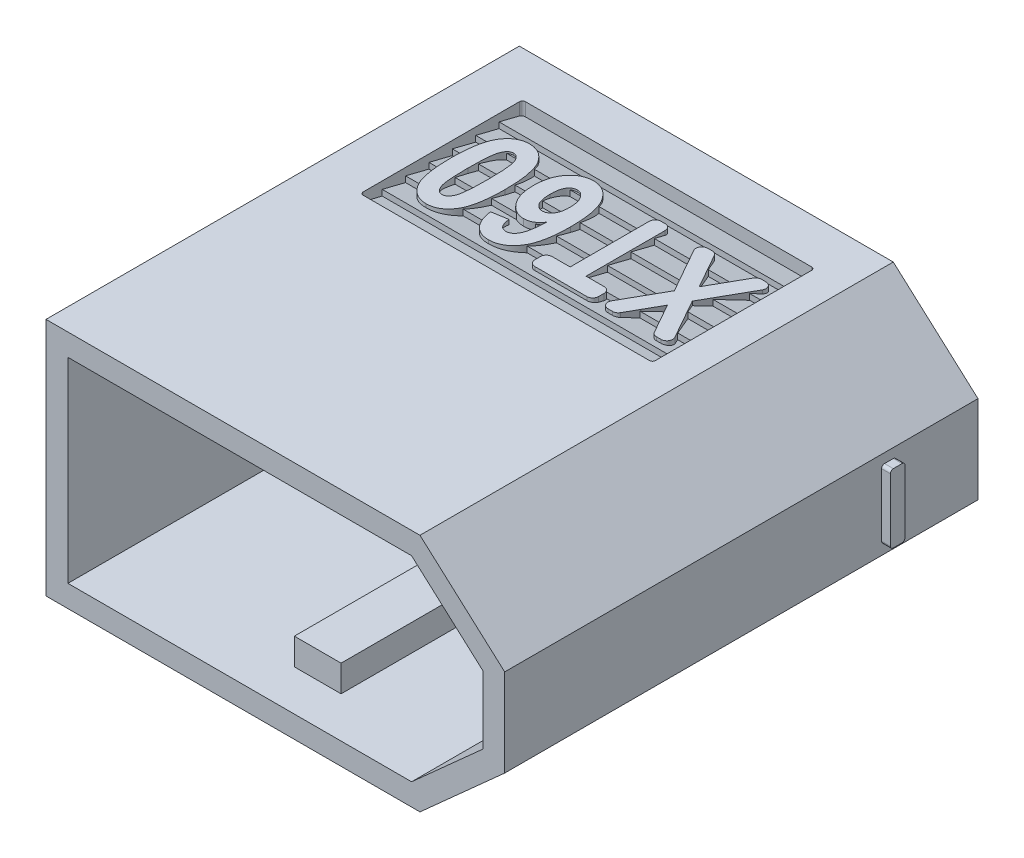
from build123d import *

# Parameters (mm, degrees)
RESSALTO_EXTRUS_O1_DEPTH = 16.2
CORTE_EXTRUS_O1_DEPTH    = 9.4
ESBO_O3_W                = 1.6
ESBO_O3_H                = 0.91
RESSALTO_EXTRUS_O2_DEPTH = 8
ESBO_O4_W                = 1.6
ESBO_O4_H                = 4.7
CORTE_EXTRUS_O2_DEPTH    = 1.5
ESBO_O5_R                = 3
CORTE_EXTRUS_O3_DEPTH    = 2
ESBO_O6_R                = 2.15
CORTE_EXTRUS_O4_DEPTH    = 15.2
RESSALTO_EXTRUS_O3_DEPTH = 0.3
RESSALTO_EXTRUS_O4_DEPTH = 0.3
CORTE_EXTRUS_O5_DEPTH    = 0.75
RESSALTO_EXTRUS_O7_DEPTH = 10
RESSALTO_EXTRUS_O8_DEPTH = 0.3
RESSALTO_EXTRUS_O9_DEPTH = 0.3


with BuildPart() as part:
    # Esboço1 → Ressalto-extrusão1 (new body)
    with BuildSketch(Plane.XY):
        Polygon((0, 0), (12.8, 0), (15.7, 2.6), (15.7, 5.6), (12.8, 8.2), (0, 8.2), align=None)
    extrude(amount=RESSALTO_EXTRUS_O1_DEPTH)

    # Esboço2 → Corte-extrusão1 (cut)
    with BuildSketch(Plane.XY.offset(16.2)):
        Polygon((0.75, 7.45), (0.75, 0.75), (12.513018725, 0.75), (14.95, 2.934879763), (14.95, 5.265120237), (12.513018725, 7.45), align=None)
    extrude(amount=-CORTE_EXTRUS_O1_DEPTH, mode=Mode.SUBTRACT)

    # Esboço3 → Ressalto-extrusão2 (add)
    with BuildSketch(Plane.XY.offset(6.8)):
        with Locations((7.9, 1.205)):
            Rectangle(ESBO_O3_W, ESBO_O3_H)
    extrude(amount=RESSALTO_EXTRUS_O2_DEPTH)

    # Esboço4 → Corte-extrusão2 (cut)
    with BuildSketch(Plane.XY.offset(6.8)):
        with Locations((7.9, 4.1)):
            Rectangle(ESBO_O4_W, ESBO_O4_H)
    extrude(amount=-CORTE_EXTRUS_O2_DEPTH, mode=Mode.SUBTRACT)

    # Esboço5 → Corte-extrusão3 (cut)
    with BuildSketch(Plane(origin=(0, 0, 0), x_dir=(-1, 0, 0), z_dir=(0, 0, -1))):
        with Locations((-11.35, 4.1)):
            Circle(ESBO_O5_R)
        with Locations((-4.25, 4.1)):
            Circle(ESBO_O5_R)
    extrude(amount=-CORTE_EXTRUS_O3_DEPTH, mode=Mode.SUBTRACT)

    # Esboço6 → Corte-extrusão4 (cut, through all)
    with BuildSketch(Plane(origin=(0, 0, 2), x_dir=(-1, 0, 0), z_dir=(0, 0, -1))):
        with Locations((-11.35, 4.1)):
            Circle(ESBO_O6_R)
        with Locations((-4.25, 4.1)):
            Circle(ESBO_O6_R)
    extrude(amount=-CORTE_EXTRUS_O4_DEPTH, mode=Mode.SUBTRACT)

    # Esboço7 → Ressalto-extrusão3 (add)
    with BuildSketch(Plane.ZY):
        with BuildLine():
            Line((2.8, 4.35), (2.05, 4.35))
            ThreePointArc((2.05, 4.35), (1.979289322, 4.320710678), (1.95, 4.25))
            Line((1.95, 4.25), (1.95, 3.95))
            ThreePointArc((1.95, 3.95), (1.979289322, 3.879289322), (2.05, 3.85))
            Line((2.05, 3.85), (2.8, 3.85))
            ThreePointArc((2.8, 3.85), (2.870710678, 3.820710678), (2.9, 3.75))
            Line((2.9, 3.75), (2.9, 3))
            ThreePointArc((2.9, 3), (2.929289322, 2.929289322), (3, 2.9))
            Line((3, 2.9), (3.3, 2.9))
            ThreePointArc((3.3, 2.9), (3.370710678, 2.929289322), (3.4, 3))
            Line((3.4, 3), (3.4, 3.75))
            ThreePointArc((3.4, 3.75), (3.429289322, 3.820710678), (3.5, 3.85))
            Line((3.5, 3.85), (4.25, 3.85))
            ThreePointArc((4.25, 3.85), (4.320710678, 3.879289322), (4.35, 3.95))
            Line((4.35, 3.95), (4.35, 4.25))
            ThreePointArc((4.35, 4.25), (4.320710678, 4.320710678), (4.25, 4.35))
            Line((4.25, 4.35), (3.5, 4.35))
            ThreePointArc((3.5, 4.35), (3.429289322, 4.379289322), (3.4, 4.45))
            Line((3.4, 4.45), (3.4, 5.2))
            ThreePointArc((3.4, 5.2), (3.370710678, 5.270710678), (3.3, 5.3))
            Line((3.3, 5.3), (3, 5.3))
            ThreePointArc((3, 5.3), (2.929289322, 5.270710678), (2.9, 5.2))
            Line((2.9, 5.2), (2.9, 4.45))
            ThreePointArc((2.9, 4.45), (2.870710678, 4.379289322), (2.8, 4.35))
        make_face()
    extrude(amount=RESSALTO_EXTRUS_O3_DEPTH)

    # Esboço8 → Ressalto-extrusão4 (add)
    with BuildSketch(Plane(origin=(15.7, 0, 0), x_dir=(0, 0, -1), z_dir=(1, 0, 0))):
        with BuildLine():
            Line((-3.2, 2.925), (-2.9, 2.925))
            ThreePointArc((-2.9, 2.925), (-2.829289322, 2.954289322), (-2.8, 3.025))
            Line((-2.8, 3.025), (-2.8, 5.175))
            ThreePointArc((-2.8, 5.175), (-2.829289322, 5.245710678), (-2.9, 5.275))
            Line((-2.9, 5.275), (-3.2, 5.275))
            ThreePointArc((-3.2, 5.275), (-3.270710678, 5.245710678), (-3.3, 5.175))
            Line((-3.3, 5.175), (-3.3, 3.025))
            ThreePointArc((-3.3, 3.025), (-3.270710678, 2.954289322), (-3.2, 2.925))
        make_face()
    extrude(amount=RESSALTO_EXTRUS_O4_DEPTH)

    # Esboço9 → Corte-extrusão5 (cut)
    with BuildSketch(Plane.XZ):
        with BuildLine():
            Line((1.75, 7.093123445), (11.55, 7.093123445))
            ThreePointArc((11.55, 7.093123445), (11.620710678, 7.063834123), (11.65, 6.993123445))
            Line((11.65, 6.993123445), (11.65, 1.643123445))
            ThreePointArc((11.65, 1.643123445), (11.620710678, 1.572412766), (11.55, 1.543123445))
            Line((11.55, 1.543123445), (1.75, 1.543123445))
            ThreePointArc((1.75, 1.543123445), (1.679289322, 1.572412766), (1.65, 1.643123445))
            Line((1.65, 1.643123445), (1.65, 6.993123445))
            ThreePointArc((1.65, 6.993123445), (1.679289322, 7.063834123), (1.75, 7.093123445))
        make_face()
    corte_extrus_o5 = extrude(amount=-CORTE_EXTRUS_O5_DEPTH, mode=Mode.SUBTRACT)

    # Esboço10 → Ressalto-extrusão7 (add)
    with BuildSketch(Plane(origin=(1.65, 0, 0), x_dir=(0, 0, -1), z_dir=(1, 0, 0))):
        Polygon((-3.143123445, 0.45), (-3.143123445, 0.25), (-2.343123445, 0.45), (-2.343123445, 0.25), (-1.543123445, 0.45), (-1.543123445, 0.75), (-7.143123445, 0.75), (-7.143123445, 0.45), (-7.143123445, 0.25), (-6.343123445, 0.45), (-6.343123445, 0.25), (-5.543123445, 0.45), (-5.543123445, 0.25), (-4.743123445, 0.45), (-4.743123445, 0.25), (-3.943123445, 0.45), (-3.943123445, 0.25), align=None)
    ressalto_extrus_o7 = extrude(amount=RESSALTO_EXTRUS_O7_DEPTH)

    # Espelhar1: Corte-extrusão5, Ressalto-extrusão7 across plane
    add(corte_extrus_o5.mirror(Plane.ZX.offset(4.1)), mode=Mode.SUBTRACT)
    add(ressalto_extrus_o7.mirror(Plane.ZX.offset(4.1)))

    # Esboço11 → Ressalto-extrusão8 (add)
    with BuildSketch(Plane(origin=(0, 0.5, 0), x_dir=(-1, 0, 0), z_dir=(0, -1, 0))):
        with BuildLine():
            add(Edge.make_bspline(
                [(-5.023961169, -6.00435038), (-5.023731287, -5.995665006), (-5.023167139, -5.974350412), (-5.020606597, -5.937326865), (-5.015634685, -5.891913541), (-5.008374694, -5.840781928), (-4.996852924, -5.786628833), (-4.98507998, -5.730621834), (-4.970342979, -5.676032154), (-4.952923205, -5.625615372), (-4.932961076, -5.58080345), (-4.908069139, -5.546064886), (-4.881021, -5.518802059), (-4.858555504, -5.515226002), (-4.848332577, -5.513598717)],
                knots=[0, 0, 0, 0, 2.6064e-05, 6.3962e-05, 0.00011129, 0.000163105, 0.000218808, 0.000277324, 0.000334811, 0.00038823, 0.000437474, 0.000480846, 0.000517214, 0.000547583, 0.000547583, 0.000547583, 0.000547583], degree=3))
            Line((-4.848332577, -5.513598717), (-4.020609309, -5.513598717))
            Line((-4.020609309, -5.513598717), (-3.49036222, -2.555643484))
            add(Edge.make_bspline(
                [(-3.49036222, -2.555643484), (-3.487094486, -2.546511208), (-3.480493928, -2.528064751), (-3.462940698, -2.502333792), (-3.435671591, -2.480838398), (-3.397551986, -2.465314687), (-3.349369795, -2.453459182), (-3.289027368, -2.44320829), (-3.214317598, -2.436547775), (-3.159289179, -2.436398815), (-3.129021098, -2.436316881)],
                knots=[0, 0, 0, 0, 2.9025e-05, 5.8628e-05, 9.2093e-05, 0.000131598, 0.000181127, 0.000240808, 0.000315062, 0.000405833, 0.000405833, 0.000405833, 0.000405833], degree=3))
            add(Edge.make_bspline(
                [(-3.129021098, -2.436316881), (-3.099590319, -2.436400624), (-3.045954651, -2.43655324), (-2.973504555, -2.44319605), (-2.916339343, -2.453001646), (-2.873392308, -2.464895138), (-2.841745516, -2.480373872), (-2.823600732, -2.503205048), (-2.815413627, -2.529106558), (-2.817188659, -2.546643114), (-2.818099667, -2.555643484)],
                knots=[0, 0, 0, 0, 8.825e-05, 0.000160831, 0.000218029, 0.000261895, 0.000294625, 0.000321528, 0.000347044, 0.000373948, 0.000373948, 0.000373948, 0.000373948], degree=3))
            Line((-2.818099667, -2.555643484), (-3.348346756, -5.513598717))
            Line((-3.348346756, -5.513598717), (-2.527346113, -5.513598717))
            add(Edge.make_bspline(
                [(-2.527346113, -5.513598717), (-2.5158995, -5.51461475), (-2.493831667, -5.516573553), (-2.472715893, -5.546733002), (-2.463160736, -5.584517711), (-2.462285798, -5.613492933), (-2.461800514, -5.629564007)],
                knots=[0, 0, 0, 0, 3.2816e-05, 6.3265e-05, 0.00010182, 0.000149836, 0.000149836, 0.000149836, 0.000149836], degree=3))
            add(Edge.make_bspline(
                [(-2.461800514, -5.629564007), (-2.461977539, -5.638813278), (-2.462407487, -5.661277307), (-2.466216965, -5.699071845), (-2.470998184, -5.745356077), (-2.478414587, -5.796958197), (-2.488582941, -5.852446205), (-2.500798033, -5.908853075), (-2.514928426, -5.964134452), (-2.534662336, -6.013696946), (-2.55458049, -6.057861337), (-2.578178377, -6.092213603), (-2.605428151, -6.117627625), (-2.627240684, -6.121178211), (-2.637429106, -6.122836655)],
                knots=[0, 0, 0, 0, 2.7744e-05, 6.7382e-05, 0.000113874, 0.000167352, 0.000223723, 0.00028306, 0.000340547, 0.000394545, 0.000443029, 0.00048523, 0.000519878, 0.000550246, 0.000550246, 0.000550246, 0.000550246], degree=3))
            Line((-2.637429106, -6.122836655), (-4.960096227, -6.122836655))
            add(Edge.make_bspline(
                [(-4.960096227, -6.122836655), (-4.969934281, -6.121426251), (-4.99037917, -6.118495228), (-5.011571026, -6.089692698), (-5.021864767, -6.050856537), (-5.023211361, -6.020983972), (-5.023961169, -6.00435038)],
                knots=[0, 0, 0, 0, 2.8744e-05, 5.9733e-05, 9.9336e-05, 0.000149093, 0.000149093, 0.000149093, 0.000149093], degree=3))
        make_face()
        with BuildLine():
            add(Edge.make_bspline(
                [(-8.005445591, -5.732084047), (-8.005233805, -5.721157588), (-8.004755518, -5.69648183), (-8.002257862, -5.656087157), (-7.997216524, -5.609824927), (-7.989672588, -5.559640101), (-7.979672262, -5.507819052), (-7.968127736, -5.455855322), (-7.954624636, -5.406442246), (-7.937593996, -5.361995207), (-7.919841845, -5.322908562), (-7.899498565, -5.292757131), (-7.878287508, -5.269109619), (-7.86042282, -5.265583769), (-7.852505861, -5.264021244)],
                knots=[0, 0, 0, 0, 3.2784e-05, 7.4037e-05, 0.000121364, 0.000172348, 0.000226241, 0.000279653, 0.000332057, 0.00037966, 0.000422509, 0.000460033, 0.000489767, 0.000513431, 0.000513431, 0.000513431, 0.000513431], degree=3))
            add(Edge.make_bspline(
                [(-7.852505861, -5.264021244), (-7.845452061, -5.264904506), (-7.829851748, -5.266857944), (-7.804797296, -5.276024895), (-7.776406148, -5.29162043), (-7.730609729, -5.322094595), (-7.661287561, -5.366554766), (-7.562598175, -5.424293206), (-7.440427841, -5.481447336), (-7.322385437, -5.522805842), (-7.215484092, -5.550613186), (-7.125251104, -5.565599411), (-7.027726856, -5.57352652), (-6.960370911, -5.575015091), (-6.925623866, -5.575783003)],
                knots=[0, 0, 0, 0, 2.1275e-05, 4.7053e-05, 7.9381e-05, 0.000118309, 0.00021202, 0.000326465, 0.000461046, 0.000615988, 0.000700978, 0.000792156, 0.000889996, 0.000994251, 0.000994251, 0.000994251, 0.000994251], degree=3))
            add(Edge.make_bspline(
                [(-6.925623866, -5.575783003), (-6.890276179, -5.575112001), (-6.820714939, -5.573791525), (-6.71881609, -5.559310648), (-6.620879787, -5.539244265), (-6.528038512, -5.508289798), (-6.439439434, -5.470183053), (-6.354808917, -5.425881372), (-6.274209796, -5.374938124), (-6.197898312, -5.317782161), (-6.125337935, -5.254656842), (-6.057780279, -5.185519577), (-5.993086757, -5.112490516), (-5.915245473, -5.00655333), (-5.827853488, -4.865004138), (-5.741758712, -4.683337999), (-5.673142777, -4.492613249), (-5.626520902, -4.295160578), (-5.595410147, -4.096109002), (-5.592019032, -3.96274579), (-5.59034237, -3.896807277)],
                knots=[0, 0, 0, 0, 0.000105965, 0.000208529, 0.000308246, 0.000405506, 0.000501502, 0.000597351, 0.000691772, 0.000787233, 0.000883122, 0.000979979, 0.001077054, 0.001175541, 0.001374003, 0.001575094, 0.001777629, 0.001980832, 0.002182981, 0.002380675, 0.002380675, 0.002380675, 0.002380675], degree=3))
            add(Edge.make_bspline(
                [(-5.59034237, -3.896807277), (-5.590871805, -3.861481942), (-5.591899808, -3.792890748), (-5.603110001, -3.693712719), (-5.620667577, -3.601229886), (-5.644851035, -3.51534807), (-5.675878531, -3.435840868), (-5.713888363, -3.363292733), (-5.757702979, -3.297278928), (-5.807513278, -3.237950776), (-5.863357452, -3.185891772), (-5.924157557, -3.139448548), (-5.992135639, -3.102310572), (-6.064487022, -3.070033176), (-6.14190109, -3.044779053), (-6.224178948, -3.027460146), (-6.310743564, -3.016057319), (-6.370129331, -3.015001296), (-6.400418746, -3.014462676)],
                knots=[0, 0, 0, 0, 0.000105935, 0.000205693, 0.000298974, 0.000388084, 0.000472974, 0.000554538, 0.000633314, 0.000710244, 0.000786339, 0.000861968, 0.0009391, 0.001018109, 0.001099426, 0.001182826, 0.001270066, 0.001360884, 0.001360884, 0.001360884, 0.001360884], degree=3))
            add(Edge.make_bspline(
                [(-6.400418746, -3.014462676), (-6.441984642, -3.015611215), (-6.525415258, -3.017916548), (-6.647858981, -3.041043496), (-6.766205581, -3.074435661), (-6.838672757, -3.110262009), (-6.874363846, -3.127906982)],
                knots=[0, 0, 0, 0, 0.00012455, 0.000249996, 0.000372822, 0.000492024, 0.000492024, 0.000492024, 0.000492024], degree=3))
            Line((-6.874363846, -3.127906982), (-7.027303577, -3.975798127))
            Line((-7.027303577, -3.975798127), (-6.405460715, -3.975798127))
            add(Edge.make_bspline(
                [(-6.405460715, -3.975798127), (-6.396032338, -3.977054064), (-6.376498001, -3.979656199), (-6.354225524, -4.004786531), (-6.340822506, -4.042285405), (-6.340248828, -4.071973018), (-6.339915116, -4.089242433)],
                knots=[0, 0, 0, 0, 2.7718e-05, 5.7428e-05, 9.4412e-05, 0.000145844, 0.000145844, 0.000145844, 0.000145844], degree=3))
            add(Edge.make_bspline(
                [(-6.339915116, -4.089242433), (-6.340007123, -4.100178481), (-6.34021529, -4.124921501), (-6.345257389, -4.164911883), (-6.350408738, -4.210435976), (-6.359386856, -4.258457362), (-6.368207285, -4.308513896), (-6.379561212, -4.358263352), (-6.393351556, -4.406000103), (-6.410607636, -4.448661231), (-6.431034, -4.484869643), (-6.451535593, -4.514643738), (-6.476695242, -4.535852891), (-6.496191515, -4.539001749), (-6.50545977, -4.540498671)],
                knots=[0, 0, 0, 0, 3.2784e-05, 7.4173e-05, 0.000120764, 0.000170222, 0.000220656, 0.000273249, 0.000323233, 0.00036958, 0.000410962, 0.0004476, 0.000478189, 0.000505907, 0.000505907, 0.000505907, 0.000505907], degree=3))
            Line((-6.50545977, -4.540498671), (-7.618054295, -4.540498671))
            add(Edge.make_bspline(
                [(-7.618054295, -4.540498671), (-7.631028748, -4.539695256), (-7.655886414, -4.538155997), (-7.690371762, -4.526433837), (-7.718598065, -4.50614808), (-7.74018276, -4.478209964), (-7.754374786, -4.44306982), (-7.760248857, -4.401532584), (-7.761457637, -4.353981025), (-7.756174688, -4.320568781), (-7.753347134, -4.302685793)],
                knots=[0, 0, 0, 0, 3.8883e-05, 7.4495e-05, 0.000107611, 0.000141735, 0.000179033, 0.000219925, 0.000266991, 0.00032119, 0.00032119, 0.00032119, 0.00032119], degree=3))
            Line((-7.753347134, -4.302685793), (-7.488643754, -2.832951787))
            add(Edge.make_bspline(
                [(-7.488643754, -2.832951787), (-7.484932567, -2.816378345), (-7.478008418, -2.785456437), (-7.46492174, -2.741793185), (-7.446178544, -2.7041663), (-7.430134023, -2.682328748), (-7.422257827, -2.671608774)],
                knots=[0, 0, 0, 0, 5.0956e-05, 9.5071e-05, 0.00013641, 0.00017627, 0.00017627, 0.00017627, 0.00017627], degree=3))
            add(Edge.make_bspline(
                [(-7.422257827, -2.671608774), (-7.416231591, -2.665574456), (-7.402120311, -2.651444251), (-7.37426183, -2.631630505), (-7.336320112, -2.612116828), (-7.271721396, -2.580005779), (-7.173655195, -2.540224112), (-7.038673137, -2.495401693), (-6.884344834, -2.453408859), (-6.714006485, -2.419933315), (-6.533346086, -2.394808927), (-6.409750166, -2.392235662), (-6.34747807, -2.390939158)],
                knots=[0, 0, 0, 0, 2.5558e-05, 5.9847e-05, 0.000101964, 0.000153451, 0.000276268, 0.000418968, 0.000580007, 0.000755685, 0.000939548, 0.001126254, 0.001126254, 0.001126254, 0.001126254], degree=3))
            add(Edge.make_bspline(
                [(-6.34747807, -2.390939158), (-6.290017279, -2.392085578), (-6.17847988, -2.394310898), (-6.016534188, -2.41097196), (-5.865393213, -2.439681829), (-5.724343707, -2.47847325), (-5.594644173, -2.53031849), (-5.474482576, -2.59117225), (-5.366924212, -2.665978248), (-5.269134234, -2.750285511), (-5.183278961, -2.846044213), (-5.107514929, -2.951618377), (-5.045184949, -3.068619941), (-4.991498741, -3.194272892), (-4.950571377, -3.330444745), (-4.92155039, -3.476194463), (-4.903510692, -3.631932588), (-4.901479969, -3.739054811), (-4.900432925, -3.794287238)],
                knots=[0, 0, 0, 0, 0.000172368, 0.000334584, 0.000487692, 0.000633478, 0.000772671, 0.000906096, 0.001036626, 0.00116469, 0.00129261, 0.001421556, 0.001553541, 0.001689482, 0.001830902, 0.001979224, 0.002134848, 0.002300497, 0.002300497, 0.002300497, 0.002300497], degree=3))
            add(Edge.make_bspline(
                [(-4.900432925, -3.794287238), (-4.900905574, -3.845294829), (-4.901844387, -3.946610285), (-4.914742729, -4.097966778), (-4.932583422, -4.247805266), (-4.958701667, -4.395928796), (-4.99253789, -4.541087834), (-5.032356058, -4.683657708), (-5.081529457, -4.821948844), (-5.13678848, -4.956828646), (-5.199584663, -5.086811605), (-5.270198263, -5.211779027), (-5.345934724, -5.33288119), (-5.430056432, -5.447884454), (-5.521068083, -5.55643969), (-5.618182845, -5.658754515), (-5.724187844, -5.75176642), (-5.835355528, -5.838862544), (-5.954599059, -5.916135709), (-6.079758992, -5.985133465), (-6.211692275, -6.045266744), (-6.350247896, -6.095365279), (-6.495259856, -6.136376965), (-6.647191877, -6.164275874), (-6.805564122, -6.182714335), (-6.913525434, -6.184799742), (-6.968480603, -6.18586127)],
                knots=[0, 0, 0, 0, 0.000152977, 0.000303855, 0.000455405, 0.00060558, 0.000754792, 0.000902424, 0.001049395, 0.001194838, 0.001339535, 0.001482126, 0.001625271, 0.001767803, 0.00190918, 0.002050037, 0.002190516, 0.002331876, 0.002473353, 0.002616271, 0.002760301, 0.002907837, 0.003057897, 0.00321183, 0.003370795, 0.003535604, 0.003535604, 0.003535604, 0.003535604], degree=3))
            add(Edge.make_bspline(
                [(-6.968480603, -6.18586127), (-7.0290792, -6.184331494), (-7.147145904, -6.18135097), (-7.317412746, -6.155941012), (-7.473193069, -6.119872726), (-7.612804056, -6.077894875), (-7.732975101, -6.029341039), (-7.819588267, -5.98510127), (-7.876269531, -5.949103523), (-7.909395725, -5.926063462), (-7.935436602, -5.907072311), (-7.960438269, -5.88640523), (-7.981066611, -5.858738461), (-7.997461203, -5.821981054), (-8.004140504, -5.77910018), (-8.004986589, -5.74861974), (-8.005445591, -5.732084047)],
                knots=[0, 0, 0, 0, 0.000181705, 0.000354024, 0.000515266, 0.000661196, 0.000790871, 0.000903628, 0.000952353, 0.000992213, 0.00102465, 0.001049077, 0.001089246, 0.001126874, 0.001168739, 0.001218382, 0.001218382, 0.001218382, 0.001218382], degree=3))
        make_face()
        with BuildLine():
            Line((-9.699547225, -3.845547257), (-9.470137629, -2.552282171))
            add(Edge.make_bspline(
                [(-9.470137629, -2.552282171), (-9.466859766, -2.543161727), (-9.460238748, -2.52473917), (-9.442946515, -2.498964908), (-9.414937846, -2.478219246), (-9.376716334, -2.463027083), (-9.328197381, -2.450399387), (-9.267224842, -2.442997509), (-9.192960802, -2.436667812), (-9.138508583, -2.436440768), (-9.108796506, -2.436316881)],
                knots=[0, 0, 0, 0, 2.9025e-05, 5.8628e-05, 9.1572e-05, 0.000131847, 0.000181376, 0.000241629, 0.000315811, 0.000404902, 0.000404902, 0.000404902, 0.000404902], degree=3))
            add(Edge.make_bspline(
                [(-9.108796506, -2.436316881), (-9.07908089, -2.4364132), (-9.025460301, -2.436587003), (-8.953170251, -2.442958428), (-8.895984093, -2.450121251), (-8.853113738, -2.462392488), (-8.821882373, -2.47787117), (-8.803149573, -2.499931887), (-8.795230917, -2.525777934), (-8.796978272, -2.543292888), (-8.797875076, -2.552282171)],
                knots=[0, 0, 0, 0, 8.9091e-05, 0.00016076, 0.000217686, 0.000261552, 0.000294282, 0.000320535, 0.000346051, 0.000372955, 0.000372955, 0.000372955, 0.000372955], degree=3))
            Line((-8.797875076, -2.552282171), (-9.027284672, -3.845547257))
            Line((-9.027284672, -3.845547257), (-8.486953645, -5.845528352))
            add(Edge.make_bspline(
                [(-8.486953645, -5.845528352), (-8.478833829, -5.87511468), (-8.464477661, -5.927424524), (-8.452459229, -5.997552522), (-8.451114009, -6.053647581), (-8.470343992, -6.090049885), (-8.495365993, -6.108483462), (-8.519933136, -6.118787125), (-8.549846675, -6.127196016), (-8.58564508, -6.132928512), (-8.62837865, -6.135711651), (-8.678523457, -6.13827363), (-8.736802258, -6.139884763), (-8.778266582, -6.140275181), (-8.80039606, -6.140483547)],
                knots=[0, 0, 0, 0, 9.1919e-05, 0.000162517, 0.000213839, 0.000257097, 0.000279282, 0.000305988, 0.000336577, 0.000372357, 0.000414508, 0.000464991, 0.000522998, 0.000589389, 0.000589389, 0.000589389, 0.000589389], degree=3))
            add(Edge.make_bspline(
                [(-8.80039606, -6.140483547), (-8.832318453, -6.140341829), (-8.888907188, -6.140090606), (-8.964273956, -6.138021895), (-9.021780456, -6.129917263), (-9.066180039, -6.120808034), (-9.098903106, -6.102781231), (-9.120223894, -6.076561798), (-9.13175067, -6.04348518), (-9.138106211, -6.019785287), (-9.141569306, -6.006871365)],
                knots=[0, 0, 0, 0, 9.5801e-05, 0.000169826, 0.000225801, 0.000270028, 0.000305051, 0.000335501, 0.000369051, 0.00040922, 0.00040922, 0.00040922, 0.00040922], degree=3))
            Line((-9.141569306, -6.006871365), (-9.363415948, -5.124526764))
            add(Edge.make_bspline(
                [(-9.363415948, -5.124526764), (-9.375252204, -5.073003414), (-9.398319243, -4.972592338), (-9.4313429, -4.82328113), (-9.459458724, -4.674488444), (-9.474906837, -4.574439649), (-9.482742551, -4.523692108)],
                knots=[0, 0, 0, 0, 0.000158597, 0.000309082, 0.000458731, 0.00061277, 0.00061277, 0.00061277, 0.00061277], degree=3))
            Line((-9.482742551, -4.523692108), (-9.487784521, -4.523692108))
            add(Edge.make_bspline(
                [(-9.487784521, -4.523692108), (-9.511639997, -4.574225455), (-9.559347354, -4.675284529), (-9.635013885, -4.824621142), (-9.714451456, -4.972922929), (-9.770445333, -5.070325057), (-9.798705951, -5.119484795)],
                knots=[0, 0, 0, 0, 0.000167637, 0.000335248, 0.000502177, 0.000672281, 0.000672281, 0.000672281, 0.000672281], degree=3))
            Line((-9.798705951, -5.119484795), (-10.326432055, -6.015274647))
            add(Edge.make_bspline(
                [(-10.326432055, -6.015274647), (-10.333247008, -6.02658162), (-10.346131701, -6.047959155), (-10.367813932, -6.077469508), (-10.397293269, -6.100071343), (-10.435252647, -6.11659373), (-10.484479232, -6.127846444), (-10.547170712, -6.136190535), (-10.628360793, -6.139453445), (-10.688895234, -6.140111868), (-10.723066962, -6.140483547)],
                knots=[0, 0, 0, 0, 3.9638e-05, 7.4942e-05, 0.000109066, 0.000149681, 0.000198187, 0.000260104, 0.000339207, 0.000441741, 0.000441741, 0.000441741, 0.000441741], degree=3))
            add(Edge.make_bspline(
                [(-10.723066962, -6.140483547), (-10.746315279, -6.140244969), (-10.789737126, -6.139799365), (-10.850571208, -6.138566379), (-10.902659649, -6.134868561), (-10.946544735, -6.131420338), (-10.982700322, -6.124853597), (-11.011731032, -6.115530144), (-11.035346625, -6.104645101), (-11.05126765, -6.088522037), (-11.061638069, -6.069687635), (-11.063660752, -6.047269133), (-11.058519319, -6.022504265), (-11.043126489, -5.98211466), (-11.009623355, -5.922933123), (-10.97952139, -5.87342411), (-10.962560496, -5.845528352)],
                knots=[0, 0, 0, 0, 6.9752e-05, 0.000130279, 0.000182488, 0.000226387, 0.000262315, 0.000292344, 0.000317902, 0.000339293, 0.000359214, 0.000381208, 0.000405109, 0.000434616, 0.000510544, 0.000608542, 0.000608542, 0.000608542, 0.000608542], degree=3))
            Line((-10.962560496, -5.845528352), (-9.699547225, -3.845547257))
        make_face()
    extrude(amount=RESSALTO_EXTRUS_O8_DEPTH)

    # Esboço12 → Ressalto-extrusão9 (add)
    with BuildSketch(Plane(origin=(0, 7.7, 0), x_dir=(1, 0, 0), z_dir=(0, 1, 0))):
        with BuildLine():
            Line((11.185044584, -2.866454717), (10.320104725, -4.398379126))
            Line((10.320104725, -4.398379126), (11.094198639, -5.769814539))
            ThreePointArc((11.094198639, -5.769814539), (11.092744365, -5.968965447), (10.920028151, -6.068123445))
            Line((10.920028151, -6.068123445), (10.7649422, -6.068123445))
            ThreePointArc((10.7649422, -6.068123445), (10.664138477, -6.040862003), (10.590815302, -5.966509539))
            Line((10.590815302, -5.966509539), (10.012576316, -4.943123445))
            Line((10.012576316, -4.943123445), (9.435030455, -5.966426179))
            ThreePointArc((9.435030455, -5.966426179), (9.361701545, -6.040837872), (9.260856483, -6.068123445))
            Line((9.260856483, -6.068123445), (9.105124481, -6.068123445))
            ThreePointArc((9.105124481, -6.068123445), (8.932408267, -5.968965447), (8.930953993, -5.769814539))
            Line((8.930953993, -5.769814539), (9.705047907, -4.398379126))
            Line((9.705047907, -4.398379126), (8.840108048, -2.866454717))
            ThreePointArc((8.840108048, -2.866454717), (8.841543221, -2.667292533), (9.01426591, -2.568123445))
            Line((9.01426591, -2.568123445), (9.169940798, -2.568123445))
            ThreePointArc((9.169940798, -2.568123445), (9.270790107, -2.595411497), (9.344119604, -2.669829276))
            Line((9.344119604, -2.669829276), (10.012576316, -3.854345035))
            Line((10.012576316, -3.854345035), (10.681728288, -2.669756355))
            ThreePointArc((10.681728288, -2.669756355), (10.755052773, -2.595390388), (10.855865922, -2.568123445))
            Line((10.855865922, -2.568123445), (11.010886722, -2.568123445))
            ThreePointArc((11.010886722, -2.568123445), (11.183609411, -2.667292533), (11.185044584, -2.866454717))
        make_face()
        with BuildLine():
            Line((7.762576316, -2.768123445), (7.762576316, -5.477214354))
            Line((7.762576316, -5.477214354), (8.380758134, -5.477214354))
            ThreePointArc((8.380758134, -5.477214354), (8.522179491, -5.535792997), (8.580758134, -5.677214354))
            Line((8.580758134, -5.677214354), (8.580758134, -5.868123445))
            ThreePointArc((8.580758134, -5.868123445), (8.522179491, -6.009544801), (8.380758134, -6.068123445))
            Line((8.380758134, -6.068123445), (6.598939953, -6.068123445))
            ThreePointArc((6.598939953, -6.068123445), (6.457518596, -6.009544801), (6.398939953, -5.868123445))
            Line((6.398939953, -5.868123445), (6.398939953, -5.677214354))
            ThreePointArc((6.398939953, -5.677214354), (6.457518596, -5.535792997), (6.598939953, -5.477214354))
            Line((6.598939953, -5.477214354), (7.217121771, -5.477214354))
            Line((7.217121771, -5.477214354), (7.217121771, -2.768123445))
            ThreePointArc((7.217121771, -2.768123445), (7.275700414, -2.626702088), (7.417121771, -2.568123445))
            Line((7.417121771, -2.568123445), (7.562576316, -2.568123445))
            ThreePointArc((7.562576316, -2.568123445), (7.703997672, -2.626702088), (7.762576316, -2.768123445))
        make_face()
        with BuildLine():
            Line((4.217121771, -5.204487081), (4.762576316, -5.11357799))
            add(Edge.make_bspline(
                [(4.762576316, -5.11357799), (4.76820949, -5.173924633), (4.781337444, -5.259439061), (4.819168165, -5.361191101), (4.853361229, -5.419789109), (4.894424887, -5.466597978), (4.961777465, -5.510957772), (5.022038471, -5.523265851), (5.062292225, -5.522668899)],
                knots=[0, 0, 0, 0, 0.323351038, 0.457031878, 0.575725889, 0.682827962, 0.785621923, 1, 1, 1, 1], degree=3))
            add(Edge.make_bspline(
                [(5.062292225, -5.522668899), (5.090005536, -5.523271256), (5.131240753, -5.516505903), (5.183240033, -5.496464747), (5.220091612, -5.475090137), (5.254809063, -5.44738128), (5.287295538, -5.413652015), (5.318784831, -5.374418203), (5.348496948, -5.327992624), (5.375862324, -5.27190132), (5.400526587, -5.204375405), (5.42080653, -5.124170881), (5.441377932, -5.032489264), (5.456741962, -4.927718403), (5.47688134, -4.763925871), (5.485298827, -4.634283794), (5.489849043, -4.543975717)],
                knots=[0, 0, 0, 0, 0.07110629, 0.106432223, 0.14303469, 0.180361233, 0.220458154, 0.263402163, 0.309743564, 0.362096385, 0.423824058, 0.494518004, 0.575001043, 0.665717727, 0.767054977, 1, 1, 1, 1], degree=3))
            add(Edge.make_bspline(
                [(5.489849043, -4.543975717), (5.458325439, -4.59029492), (5.407025482, -4.654615722), (5.327609617, -4.725483765), (5.267100836, -4.768088661), (5.202789438, -4.800226136), (5.112590312, -4.832606749), (5.040111771, -4.83988466), (4.991979725, -4.840850717)],
                knots=[0, 0, 0, 0, 0.277998008, 0.405177954, 0.526602292, 0.643637452, 0.760548992, 1, 1, 1, 1], degree=3))
            add(Edge.make_bspline(
                [(4.991979725, -4.840850717), (4.938397795, -4.840049228), (4.857644594, -4.832427325), (4.755876709, -4.798007625), (4.682335645, -4.763632003), (4.610596897, -4.720231075), (4.542640345, -4.665558625), (4.476889163, -4.601961344), (4.414752476, -4.529006286), (4.357734038, -4.448067208), (4.307371702, -4.360004902), (4.266071161, -4.265189584), (4.230469873, -4.164568314), (4.205010426, -4.057053869), (4.1786726, -3.902079336), (4.170937798, -3.781658743), (4.171667225, -3.69951549)],
                knots=[0, 0, 0, 0, 0.103373273, 0.154207333, 0.205955138, 0.259297376, 0.315055498, 0.373346508, 0.435038939, 0.499094576, 0.56354236, 0.62980043, 0.697776404, 0.768573701, 0.842016383, 1, 1, 1, 1], degree=3))
            add(Edge.make_bspline(
                [(4.171667225, -3.69951549), (4.17185896, -3.612421658), (4.179060828, -3.485146498), (4.205900348, -3.321369203), (4.234396433, -3.20963002), (4.2696034, -3.104366118), (4.314707671, -3.007473367), (4.366288245, -2.916922605), (4.426957594, -2.835664661), (4.492885026, -2.762488286), (4.56321129, -2.698010574), (4.638016826, -2.644053991), (4.716117978, -2.599205297), (4.798442704, -2.564863658), (4.914867128, -2.532610579), (5.005897079, -2.522349793), (5.067263816, -2.522668899)],
                knots=[0, 0, 0, 0, 0.157846943, 0.230497149, 0.300424491, 0.366636184, 0.431332033, 0.493808926, 0.555163499, 0.614703094, 0.672106668, 0.727718583, 0.781520235, 0.834985538, 0.88891022, 1, 1, 1, 1], degree=3))
            add(Edge.make_bspline(
                [(5.067263816, -2.522668899), (5.134776318, -2.522388948), (5.235013241, -2.535219464), (5.362092148, -2.577511404), (5.451550186, -2.622540527), (5.536655096, -2.680446511), (5.616741921, -2.751072456), (5.692332527, -2.834441462), (5.763971124, -2.930110778), (5.82918472, -3.04081959), (5.883929661, -3.168816952), (5.931571611, -3.312472802), (5.969029009, -3.473320865), (5.999665981, -3.650168244), (6.028262771, -3.919162037), (6.035311504, -4.129776969), (6.035303589, -4.275509808)],
                knots=[0, 0, 0, 0, 0.090693495, 0.134685131, 0.179530034, 0.224912922, 0.272737739, 0.322760271, 0.375986421, 0.433203955, 0.495069598, 0.562818628, 0.636478469, 0.716917714, 0.804030531, 1, 1, 1, 1], degree=3))
            add(Edge.make_bspline(
                [(6.035303589, -4.275509808), (6.035321208, -4.423581802), (6.028586042, -4.637939475), (5.997249035, -4.911199563), (5.966641992, -5.091655496), (5.926254815, -5.255456188), (5.877882298, -5.403133674), (5.820063121, -5.534267496), (5.751835344, -5.647887006), (5.677444095, -5.746891367), (5.597624044, -5.832519938), (5.513228762, -5.905957941), (5.422406745, -5.96445997), (5.327623343, -6.011484887), (5.191786058, -6.055622146), (5.084345761, -6.068641489), (5.011866089, -6.068123445)],
                knots=[0, 0, 0, 0, 0.192657569, 0.278521348, 0.357596923, 0.430563241, 0.497752602, 0.559502274, 0.616536619, 0.669746994, 0.720292489, 0.768554988, 0.814846956, 0.860430936, 0.905808517, 1, 1, 1, 1], degree=3))
            add(Edge.make_bspline(
                [(5.011866089, -6.068123445), (4.961903446, -6.06789345), (4.888028114, -6.061626473), (4.793001037, -6.039603881), (4.725795095, -6.016102048), (4.661944049, -5.985106158), (4.600204149, -5.948907027), (4.541772821, -5.905419857), (4.487247773, -5.854566598), (4.43554269, -5.798076733), (4.390262811, -5.733146732), (4.348758109, -5.662053174), (4.313065822, -5.583489418), (4.280538021, -5.498839828), (4.24537643, -5.372392174), (4.226035204, -5.273167916), (4.217121771, -5.204487081)],
                knots=[0, 0, 0, 0, 0.115543302, 0.170649433, 0.225187049, 0.279790566, 0.334525644, 0.390473716, 0.447810616, 0.506730268, 0.567186295, 0.630471054, 0.696846024, 0.766492743, 0.839958973, 1, 1, 1, 1], degree=3))
        make_face()
        with BuildLine():
            add(Edge.make_bspline(
                [(5.444394498, -3.721532535), (5.443413243, -3.671816504), (5.441774499, -3.598919405), (5.428964767, -3.50575196), (5.416513606, -3.442460626), (5.39901126, -3.384318695), (5.379738685, -3.329960639), (5.355461716, -3.280752232), (5.327421984, -3.236743151), (5.298038654, -3.197058094), (5.266817632, -3.162801594), (5.234319039, -3.134257306), (5.201874492, -3.109517602), (5.167408759, -3.090781113), (5.119948206, -3.073930539), (5.082776396, -3.068257967), (5.058030862, -3.068123445)],
                knots=[0, 0, 0, 0, 0.178482482, 0.260708928, 0.336947951, 0.40946762, 0.47821344, 0.543503214, 0.605672981, 0.665087478, 0.720355931, 0.771459165, 0.820010483, 0.866344773, 0.911449985, 1, 1, 1, 1], degree=3))
            add(Edge.make_bspline(
                [(5.058030862, -3.068123445), (5.011333584, -3.067304655), (4.939791649, -3.085797467), (4.86264655, -3.146956505), (4.819952016, -3.197224746), (4.79035383, -3.246363095), (4.770537869, -3.289704134), (4.754443985, -3.338919978), (4.740189246, -3.393143293), (4.729596718, -3.453239822), (4.72052411, -3.544234997), (4.716316659, -3.615360982), (4.717121771, -3.664714354)],
                knots=[0, 0, 0, 0, 0.182717956, 0.277311697, 0.381920987, 0.439334057, 0.501576805, 0.568145713, 0.64192066, 0.721049878, 0.806868135, 1, 1, 1, 1], degree=3))
            add(Edge.make_bspline(
                [(4.717121771, -3.664714354), (4.717023666, -3.715881874), (4.71928254, -3.790108644), (4.731260972, -3.884669406), (4.742289738, -3.947647624), (4.757256441, -4.005038937), (4.774726651, -4.057271853), (4.795918712, -4.103878339), (4.828454634, -4.156184323), (4.87337471, -4.211354153), (4.957448965, -4.275083227), (5.032786713, -4.296660278), (5.082888816, -4.295396172)],
                knots=[0, 0, 0, 0, 0.189207564, 0.273855027, 0.352111634, 0.425324443, 0.49283636, 0.555472207, 0.61399486, 0.72019415, 0.816437051, 1, 1, 1, 1], degree=3))
            add(Edge.make_bspline(
                [(5.082888816, -4.295396172), (5.131526314, -4.295488538), (5.205689597, -4.276323592), (5.287703716, -4.214653218), (5.333020871, -4.162954728), (5.365244164, -4.113471075), (5.386562707, -4.070535517), (5.404216359, -4.023081599), (5.419178051, -3.971365378), (5.430172085, -3.91499019), (5.442161504, -3.831586596), (5.444525217, -3.766315864), (5.444394498, -3.721532535)],
                knots=[0, 0, 0, 0, 0.192976457, 0.293260508, 0.40387877, 0.464412825, 0.527516319, 0.593906739, 0.665362139, 0.741185596, 0.82193725, 1, 1, 1, 1], degree=3))
        make_face(mode=Mode.SUBTRACT)
        with BuildLine():
            add(Edge.make_bspline(
                [(2.877633134, -6.068123445), (2.810730433, -6.067849084), (2.711314347, -6.056349671), (2.585994956, -6.0147115), (2.498310016, -5.971140602), (2.415902857, -5.914953241), (2.338568607, -5.846563404), (2.266246061, -5.765980633), (2.198470254, -5.672487326), (2.137564732, -5.563141791), (2.085547014, -5.43597675), (2.041861983, -5.290553015), (2.006259497, -5.126888157), (1.978040904, -4.944750096), (1.951290686, -4.665360773), (1.9446089, -4.446077253), (1.944394498, -4.293975717)],
                knots=[0, 0, 0, 0, 0.089720065, 0.13287086, 0.176439702, 0.220535808, 0.266180481, 0.314487638, 0.365396204, 0.420661105, 0.481833882, 0.5491908, 0.623951051, 0.706174952, 0.796103949, 1, 1, 1, 1], degree=3))
            add(Edge.make_bspline(
                [(1.944394498, -4.293975717), (1.944638719, -4.142353226), (1.951233344, -3.923761612), (1.97812578, -3.645109231), (2.006115325, -3.463394365), (2.042144964, -3.299848), (2.08521413, -3.154455192), (2.137775908, -3.027506965), (2.19840458, -2.918257183), (2.26630614, -2.825073804), (2.337841143, -2.744006751), (2.415214295, -2.675842312), (2.497463758, -2.619864691), (2.584721063, -2.575889294), (2.709503059, -2.534751072), (2.808285478, -2.522615935), (2.874792225, -2.522668899)],
                knots=[0, 0, 0, 0, 0.20374449, 0.293570465, 0.37598958, 0.450616808, 0.518437924, 0.579462338, 0.634858447, 0.685887879, 0.734097166, 0.779850207, 0.824051004, 0.867438546, 0.910691788, 1, 1, 1, 1], degree=3))
            add(Edge.make_bspline(
                [(2.874792225, -2.522668899), (2.941484266, -2.523710824), (3.041281588, -2.533299712), (3.166214895, -2.575602655), (3.254335121, -2.618030045), (3.336271187, -2.674506287), (3.413868558, -2.742018188), (3.486229751, -2.821916845), (3.541301575, -2.897840806), (3.58269805, -2.96498955), (3.611578144, -3.021150661), (3.638494695, -3.081976307), (3.664404568, -3.147121215), (3.686601305, -3.217861571), (3.708035904, -3.292850452), (3.727138607, -3.372484959), (3.744019269, -3.456881892), (3.759963805, -3.545815866), (3.772136852, -3.639993555), (3.784042777, -3.73839755), (3.79197113, -3.841982247), (3.799364724, -3.949918137), (3.805668325, -4.103578693), (3.808979936, -4.221020489), (3.808030862, -4.30107799)],
                knots=[0, 0, 0, 0, 0.089417833, 0.132451122, 0.17576164, 0.219737665, 0.265049642, 0.312990798, 0.36350462, 0.390208605, 0.418376443, 0.447842402, 0.479107586, 0.512034425, 0.546898156, 0.583358489, 0.621466834, 0.661945644, 0.704106633, 0.74838679, 0.794432191, 0.842955807, 0.893007524, 1, 1, 1, 1], degree=3))
            add(Edge.make_bspline(
                [(3.808030862, -4.30107799), (3.807817856, -4.452232991), (3.801141288, -4.670100701), (3.77439671, -4.947596735), (3.746123955, -5.128547937), (3.710429855, -5.2914618), (3.667063402, -5.436528845), (3.614663538, -5.563289526), (3.554017471, -5.672534186), (3.486120024, -5.765718776), (3.414584018, -5.846785534), (3.337211115, -5.914950047), (3.254961588, -5.970927649), (3.1677043, -6.014903051), (3.042922298, -6.056041271), (2.944139883, -6.068176409), (2.877633134, -6.068123445)],
                knots=[0, 0, 0, 0, 0.203492419, 0.293170916, 0.375115996, 0.449884158, 0.517528497, 0.578668156, 0.63416888, 0.68529468, 0.73359501, 0.779434455, 0.823718726, 0.867188205, 0.91052313, 1, 1, 1, 1], degree=3))
        make_face()
        with BuildLine():
            add(Edge.make_bspline(
                [(2.87621268, -5.522668899), (2.901364042, -5.522485609), (2.939097549, -5.515660071), (2.985335807, -5.493598364), (3.017683977, -5.469594025), (3.047216064, -5.438647253), (3.075339951, -5.401740483), (3.101506106, -5.358172557), (3.12641129, -5.306134624), (3.149342747, -5.241231001), (3.166151656, -5.159207953), (3.182876915, -5.059800058), (3.194653181, -4.94184505), (3.205633471, -4.805970595), (3.214801743, -4.587864315), (3.217213683, -4.415214807), (3.217121771, -4.293975717)],
                knots=[0, 0, 0, 0, 0.054971734, 0.082543038, 0.111449392, 0.142585763, 0.175843141, 0.212799818, 0.253577709, 0.301907888, 0.362981983, 0.436474838, 0.522452758, 0.62221279, 0.734739184, 1, 1, 1, 1], degree=3))
            add(Edge.make_bspline(
                [(3.217121771, -4.293975717), (3.21723583, -4.172972758), (3.214784306, -4.000561073), (3.205636937, -3.782690927), (3.1946447, -3.646816985), (3.182924905, -3.529093066), (3.166201502, -3.430144515), (3.149194996, -3.348656915), (3.126599369, -3.284100945), (3.10136876, -3.232430205), (3.075070877, -3.189035557), (3.047700598, -3.151480559), (3.017409268, -3.12122859), (2.985369959, -3.097161665), (2.939075289, -3.075153336), (2.90137521, -3.068296168), (2.87621268, -3.068123445)],
                knots=[0, 0, 0, 0, 0.265261864, 0.37800881, 0.477964371, 0.564110808, 0.637235602, 0.697923266, 0.746348172, 0.786738496, 0.823767607, 0.857503931, 0.888332168, 0.917295178, 0.944920522, 1, 1, 1, 1], degree=3))
            add(Edge.make_bspline(
                [(2.87621268, -3.068123445), (2.850853743, -3.06826339), (2.812769868, -3.074946916), (2.766299747, -3.09740445), (2.733342983, -3.120920239), (2.703673517, -3.152483033), (2.674972494, -3.18923417), (2.649713603, -3.233592599), (2.624355717, -3.285184399), (2.602790537, -3.350256609), (2.58540287, -3.431527346), (2.568868237, -3.530529492), (2.556880667, -3.647964997), (2.547054602, -3.783677003), (2.537421398, -4.001016412), (2.53533009, -4.17322022), (2.535303589, -4.293975717)],
                knots=[0, 0, 0, 0, 0.055564279, 0.083173738, 0.112539997, 0.143719458, 0.177750147, 0.214491628, 0.255325951, 0.303553145, 0.364205914, 0.437288662, 0.523385566, 0.622727249, 0.735409366, 1, 1, 1, 1], degree=3))
            add(Edge.make_bspline(
                [(2.535303589, -4.293975717), (2.535358365, -4.415203081), (2.537372615, -4.587884379), (2.547093196, -4.805928634), (2.55683239, -4.941884397), (2.568925317, -5.059781156), (2.58543415, -5.159253805), (2.602692398, -5.241029088), (2.624346813, -5.306328369), (2.64975742, -5.357875374), (2.674734641, -5.402217911), (2.703911573, -5.438360922), (2.733316363, -5.469892787), (2.766306204, -5.493382877), (2.812765639, -5.515848713), (2.850855904, -5.522527274), (2.87621268, -5.522668899)],
                knots=[0, 0, 0, 0, 0.265054696, 0.377493652, 0.477137187, 0.563048299, 0.636484046, 0.697510684, 0.745633806, 0.786380011, 0.823042207, 0.85659068, 0.887702857, 0.917005746, 0.944555625, 1, 1, 1, 1], degree=3))
        make_face(mode=Mode.SUBTRACT)
    extrude(amount=RESSALTO_EXTRUS_O9_DEPTH)


solid = part.part
